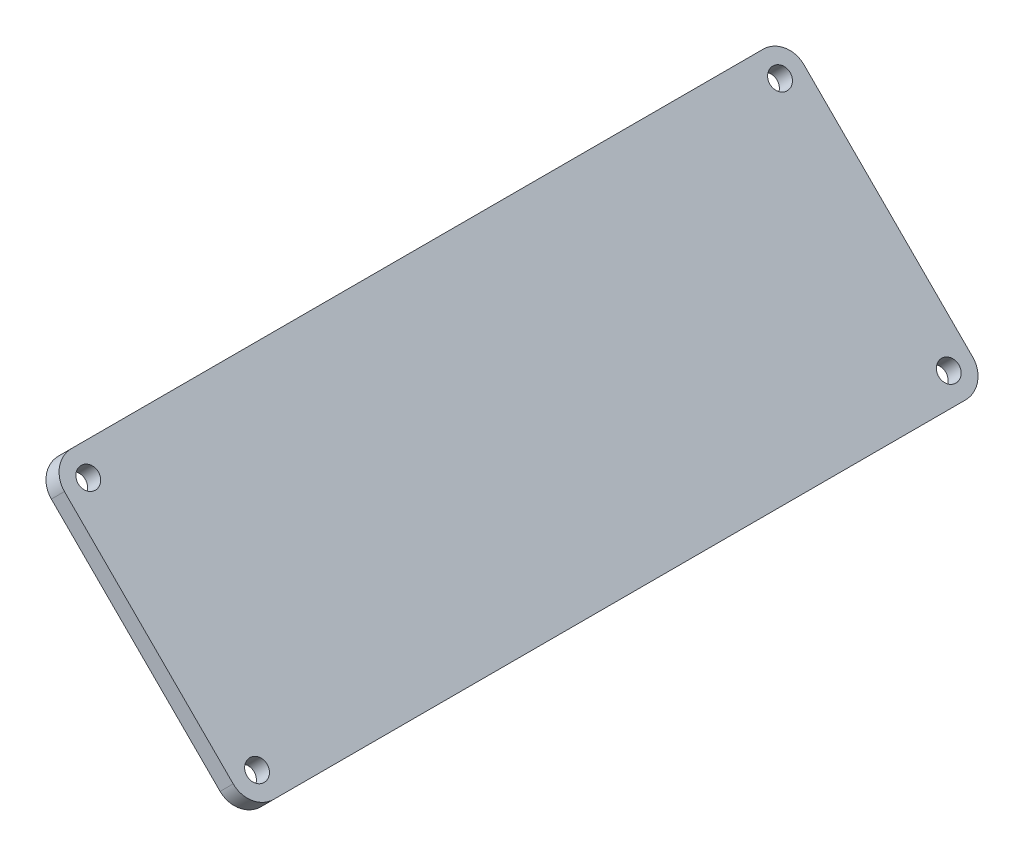
from build123d import *

# Parameters (mm, degrees)
SKETCH1_R           = 1.7
BOSS_EXTRUDE1_DEPTH = 3.1


with BuildPart() as part:
    # Sketch1 → Boss-Extrude1 (new body)
    with BuildSketch(Plane(origin=(421.898253235, 421.898253235, 0), x_dir=(0, 0, -1), z_dir=(0.707106781, 0.707106781, 0))):
        with BuildLine():
            Line((-449.269437623, 39.54937482), (-449.269437623, 79.56937482))
            ThreePointArc((-449.269437623, 79.56937482), (-450.441010499, 82.397801944), (-453.269437623, 83.56937482))
            Line((-453.269437623, 83.56937482), (-569.269437623, 83.56937482))
            ThreePointArc((-569.269437623, 83.56937482), (-572.097864748, 82.397801944), (-573.269437623, 79.56937482))
            Line((-573.269437623, 79.56937482), (-573.269437623, 39.54937482))
            ThreePointArc((-573.269437623, 39.54937482), (-572.097864748, 36.720947695), (-569.269437623, 35.54937482))
            Line((-569.269437623, 35.54937482), (-453.269437623, 35.54937482))
            ThreePointArc((-453.269437623, 35.54937482), (-450.441010499, 36.720947695), (-449.269437623, 39.54937482))
        make_face()
        with Locations((-569.269437623, 79.56937482)):
            Circle(SKETCH1_R, mode=Mode.SUBTRACT)
        with Locations((-569.269437623, 39.54937482)):
            Circle(SKETCH1_R, mode=Mode.SUBTRACT)
        with Locations((-453.269437623, 39.54937482)):
            Circle(SKETCH1_R, mode=Mode.SUBTRACT)
        with Locations((-453.269437623, 79.56937482)):
            Circle(SKETCH1_R, mode=Mode.SUBTRACT)
    extrude(amount=BOSS_EXTRUDE1_DEPTH)


solid = part.part
